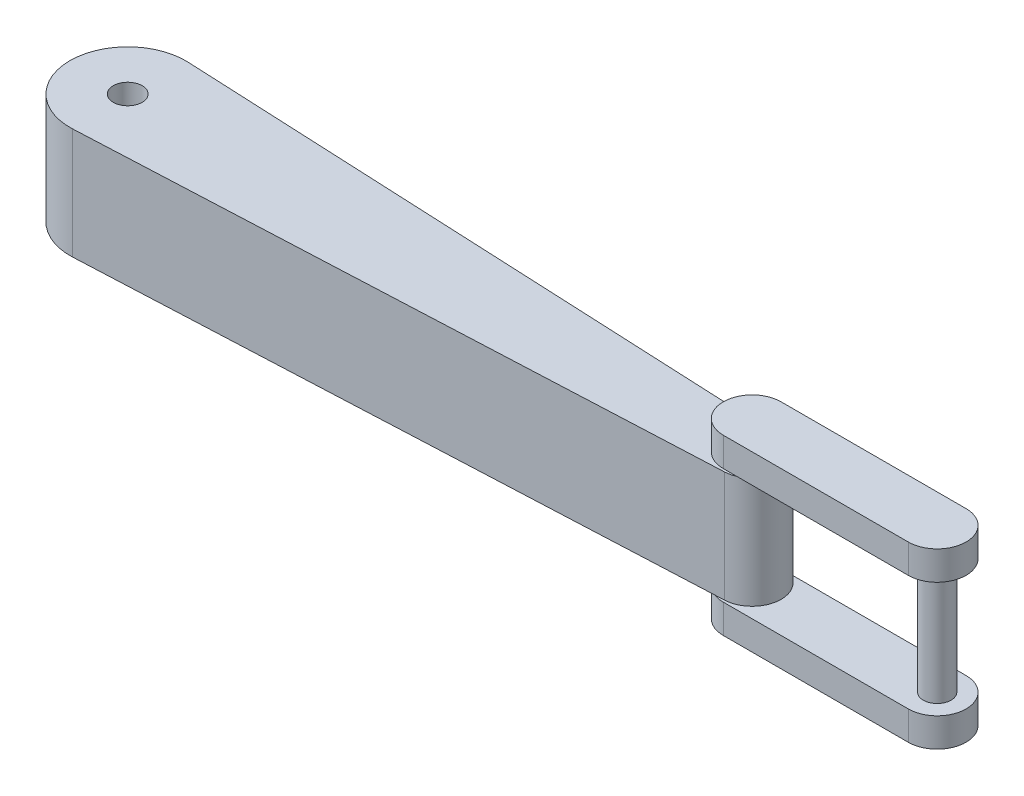
from build123d import *

# Parameters (mm, degrees)
BOSS_EXTRUDE1_DEPTH      = 24
BOSS_EXTRUDE1_DEPTH_BACK = 24
SKETCH2_R                = 6.25
BOSS_EXTRUDE2_START      = 1
BOSS_EXTRUDE2_DEPTH      = 12.5
BOSS_EXTRUDE4_DEPTH      = 10
BOSS_EXTRUDE4_DEPTH_BACK = 54
SKETCH5_R                = 5
BOSS_EXTRUDE5_DEPTH      = 31
BOSS_EXTRUDE5_DEPTH_BACK = 30
SKETCH6_R                = 6


with BuildPart() as part:
    # Sketch2 → Boss-Extrude1 (new, two sides: drawn at the far end of the back side and taken through both)
    with BuildSketch(Plane(origin=(0, 0, 0), x_dir=(1, 0, 0), z_dir=(0, 1, 0)).offset(-BOSS_EXTRUDE1_DEPTH_BACK)):
        with BuildLine():
            Line((270.578703704, 12.486596895), (1.157407407, 24.97319379))
            ThreePointArc((1.157407407, 24.97319379), (-25, 0), (1.157407407, -24.97319379))
            Line((1.157407407, -24.97319379), (270.578703704, -12.486596895))
            ThreePointArc((270.578703704, -12.486596895), (282.5, 0), (270.578703704, 12.486596895))
        make_face()
        Circle(SKETCH2_R, mode=Mode.SUBTRACT)
    extrude(amount=BOSS_EXTRUDE1_DEPTH + BOSS_EXTRUDE1_DEPTH_BACK)



with BuildPart() as body_2:
    # Sketch3 → Boss-Extrude2 (new body)
    with BuildSketch(Plane(origin=(0, 24, 0), x_dir=(1, 0, 0), z_dir=(0, 1, 0)).offset(BOSS_EXTRUDE2_START)):
        with BuildLine():
            Line((270, 12.5), (350, 12.5))
            ThreePointArc((350, 12.5), (362.5, 0), (350, -12.5))
            Line((350, -12.5), (270, -12.5))
            ThreePointArc((270, -12.5), (257.5, 0), (270, 12.5))
        make_face()
    boss_extrude2 = extrude(amount=BOSS_EXTRUDE2_DEPTH)


with BuildPart() as part_1:
    add(part.part)

    add(body_2.part)  # Boss-Extrude4 merges body 2
    # Sketch5 → Boss-Extrude4 (add, two sides: drawn at the far end of the back side and taken through both)
    with BuildSketch(Plane.XZ.offset(24).offset(-BOSS_EXTRUDE4_DEPTH_BACK)):
        with Locations((270, 0)):
            Circle(SKETCH5_R)
    extrude(amount=BOSS_EXTRUDE4_DEPTH + BOSS_EXTRUDE4_DEPTH_BACK)

    # Mirror1: Boss-Extrude2 across plane
    add(boss_extrude2.mirror(Plane.ZX))

    # Sketch6 → Boss-Extrude5 (add, two sides: drawn at the far end of the back side and taken through both)
    with BuildSketch(Plane(origin=(0, 0, 0), x_dir=(1, 0, 0), z_dir=(0, 1, 0)).offset(-BOSS_EXTRUDE5_DEPTH_BACK)):
        with Locations((350, 0)):
            Circle(SKETCH6_R)
    extrude(amount=BOSS_EXTRUDE5_DEPTH + BOSS_EXTRUDE5_DEPTH_BACK)


solid = part_1.part
